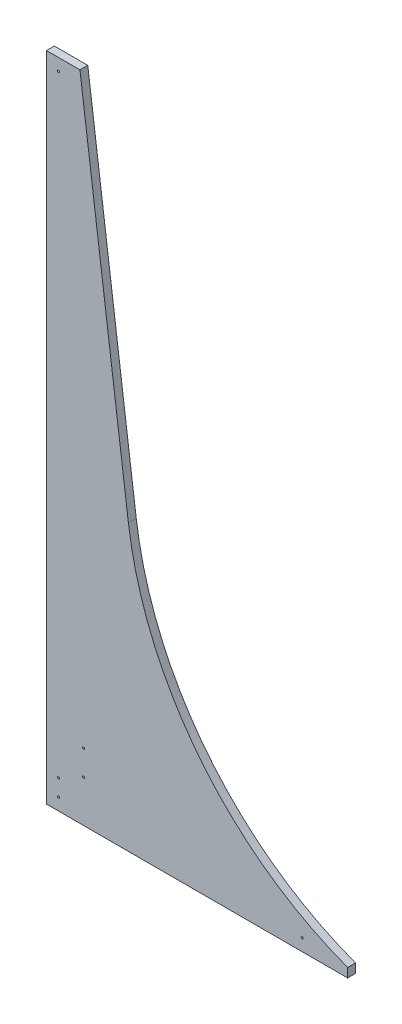
from build123d import *

# Parameters (mm, degrees)
SKETCH1_R           = 1.5875
BOSS_EXTRUDE1_DEPTH = 11.90625


with BuildPart() as part:
    # Sketch1 → Boss-Extrude1 (new body)
    with BuildSketch(Plane.XY):
        with BuildLine():
            Line((0, 990.6), (0, 0))
            Line((0, 0), (457.201, 0))
            Line((457.201, 0), (457.201, 13.862038208))
            ThreePointArc((457.201, 13.862038208), (232.767577124, 176.628269142), (124.367415652, 431.8))
            Line((124.367415652, 431.8), (50.8, 990.6))
            Line((50.8, 990.6), (0, 990.6))
        make_face()
        with Locations((18.25625, 18.25625)):
            Circle(SKETCH1_R, mode=Mode.SUBTRACT)
        with Locations((18.25625, 43.65625)):
            Circle(SKETCH1_R, mode=Mode.SUBTRACT)
        with Locations((56.35625, 63.5)):
            Circle(SKETCH1_R, mode=Mode.SUBTRACT)
        with Locations((56.35625, 101.6)):
            Circle(SKETCH1_R, mode=Mode.SUBTRACT)
        with Locations((388.14375, 18.25625)):
            Circle(SKETCH1_R, mode=Mode.SUBTRACT)
        with Locations((18.25625, 972.34375)):
            Circle(SKETCH1_R, mode=Mode.SUBTRACT)
    extrude(amount=BOSS_EXTRUDE1_DEPTH)


solid = part.part
